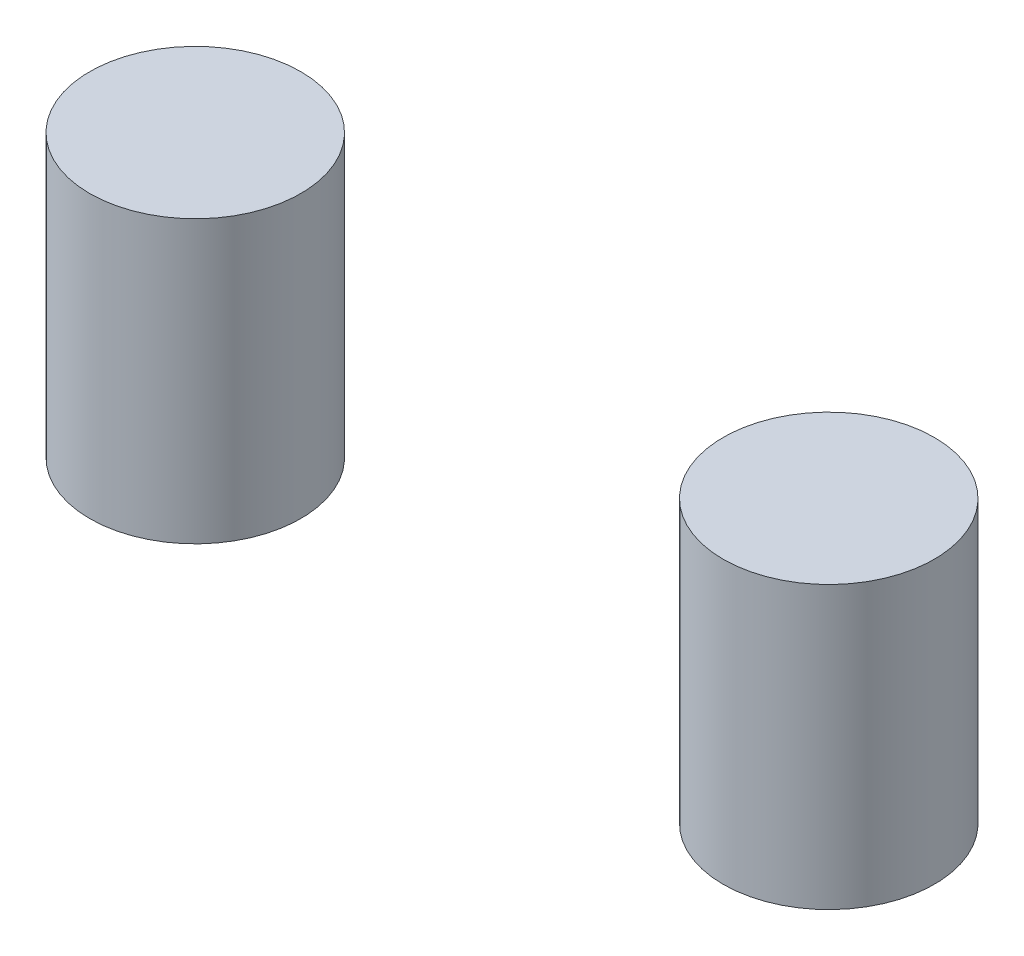
from build123d import *

# Parameters (mm, degrees)
SKETCH_1_R        = 30
EXTRUDE_1_DEPTH   = 80
EXTRUDE_1_2_DEPTH = 80


with BuildPart() as part:
    # 草图1 → 凸台-拉伸1 (new body)
    with BuildSketch(Plane(origin=(0, 0, 0), x_dir=(1, 0, 0), z_dir=(0, 1, 0))):
        with Locations((-90, 0)):
            Circle(SKETCH_1_R)
    extrude(amount=EXTRUDE_1_DEPTH)


with BuildPart() as body_2:
    # 草图1 → Extrude 1 2 (new body)
    with BuildSketch(Plane(origin=(0, 0, 0), x_dir=(1, 0, 0), z_dir=(0, 1, 0))):
        with Locations((90, 0)):
            Circle(SKETCH_1_R)
    extrude(amount=EXTRUDE_1_2_DEPTH)


solid = Compound([part.part, body_2.part])
